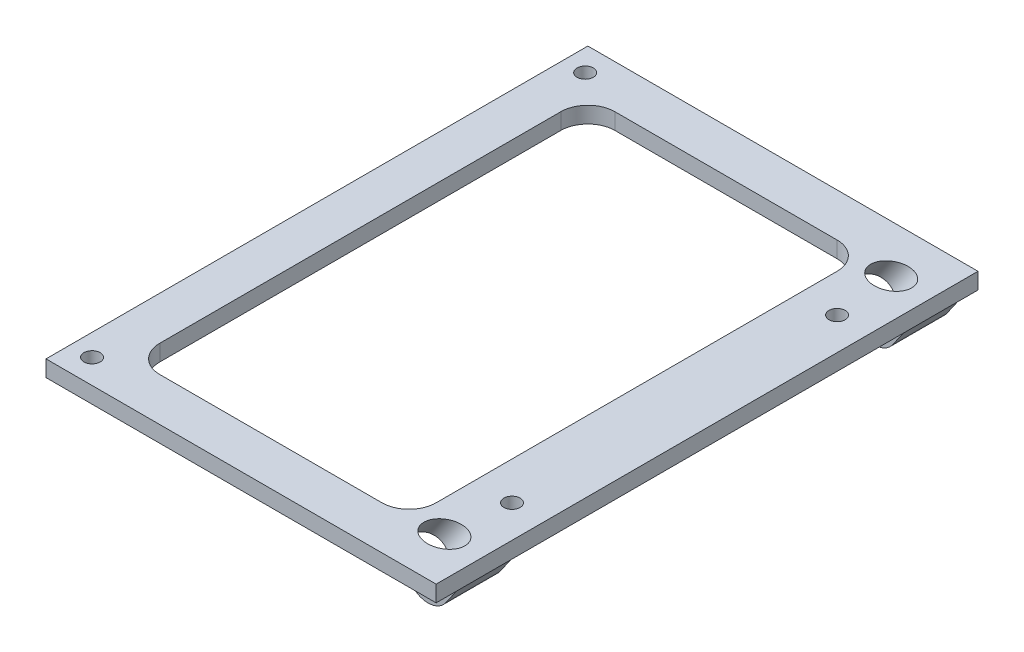
from build123d import *

# Parameters (mm, degrees)
SKETCH1_W           = 72
SKETCH1_H           = 100
SKETCH1_R           = 1.5
BOSS_EXTRUDE1_DEPTH = 3
SKETCH3_W           = 13
SKETCH3_H           = 10
BOSS_EXTRUDE3_DEPTH = 11
CUT_EXTRUDE1_DEPTH  = 15
SKETCH6_R           = 3.1
CUT_EXTRUDE2_DEPTH  = 10.913949805
FILLET1_R           = 4
SKETCH7_R           = 1.5
CUT_EXTRUDE3_DEPTH  = 8.537088113


with BuildPart() as part:
    # Sketch1 → Boss-Extrude1 (new body)
    with BuildSketch(Plane.XZ):
        with Locations((39, 0)):
            Rectangle(SKETCH1_W, SKETCH1_H)
        with Locations((7, -45.5)):
            Circle(SKETCH1_R, mode=Mode.SUBTRACT)
        with BuildLine():
            Line((62, 37), (62, -37))
            ThreePointArc((62, -37), (60.535533906, -40.535533906), (57, -42))
            Line((57, -42), (16, -42))
            ThreePointArc((16, -42), (12.464466094, -40.535533906), (11, -37))
            Line((11, -37), (11, 37))
            ThreePointArc((11, 37), (12.464466094, 40.535533906), (16, 42))
            Line((16, 42), (57, 42))
            ThreePointArc((57, 42), (60.535533906, 40.535533906), (62, 37))
        make_face(mode=Mode.SUBTRACT)
        with Locations((7, 45.5)):
            Circle(SKETCH1_R, mode=Mode.SUBTRACT)
    extrude(amount=BOSS_EXTRUDE1_DEPTH)

    # Sketch3 → Boss-Extrude3 (add)
    with BuildSketch(Plane.XZ.offset(3)):
        with Locations((68.5, -41.227292579)):
            Rectangle(SKETCH3_W, SKETCH3_H)
    boss_extrude3 = extrude(amount=BOSS_EXTRUDE3_DEPTH)

    # Sketch4 → Cut-Extrude1 (cut)
    with BuildSketch(Plane(origin=(0, 0, -46.227292579), x_dir=(-1, 0, 0), z_dir=(0, 0, -1))):
        Polygon((-62, -14), (-62, -3), (-70.723130932, -9.108002035), (-67.29771708, -14), align=None)
        Polygon((-67.29771708, -14), (-70.723130932, -9.108002035), (-75, -3), (-75, -14), align=None)
    cut_extrude1 = extrude(amount=-CUT_EXTRUDE1_DEPTH, mode=Mode.SUBTRACT)

    # Sketch6 → Cut-Extrude2 (cut, through all)
    with BuildSketch(Plane(origin=(18.987836626, 27.117441029, 0), x_dir=(0.819152044, -0.573576436, 0), z_dir=(-0.573576436, -0.819152044, 0))):
        with Locations((55.50325926, -41.227292579)):
            Circle(SKETCH6_R)
    cut_extrude2 = extrude(amount=-CUT_EXTRUDE2_DEPTH, mode=Mode.SUBTRACT)

    # Mirror1: Boss-Extrude3, Cut-Extrude1, Cut-Extrude2 across plane
    add(boss_extrude3.mirror(Plane.XY))
    add(cut_extrude1.mirror(Plane.XY), mode=Mode.SUBTRACT)
    add(cut_extrude2.mirror(Plane.XY), mode=Mode.SUBTRACT)

    # Fillet1
    fillet1_edges = [part.edges().sort_by_distance(p)[0] for p in [
        (70.723130932, -9.108002035, 41.227292579),
        (70.723130932, -9.108002035, -41.227292579),
    ]]
    fillet(fillet1_edges, radius=FILLET1_R)

    # Sketch7 → Cut-Extrude3 (cut, through all)
    with BuildSketch(Plane(origin=(0, 0, 0), x_dir=(1, 0, 0), z_dir=(0, 1, 0))):
        with Locations((69, 30)):
            Circle(SKETCH7_R)
        with Locations((69, -30)):
            Circle(SKETCH7_R)
    extrude(amount=-CUT_EXTRUDE3_DEPTH, mode=Mode.SUBTRACT)


solid = part.part
